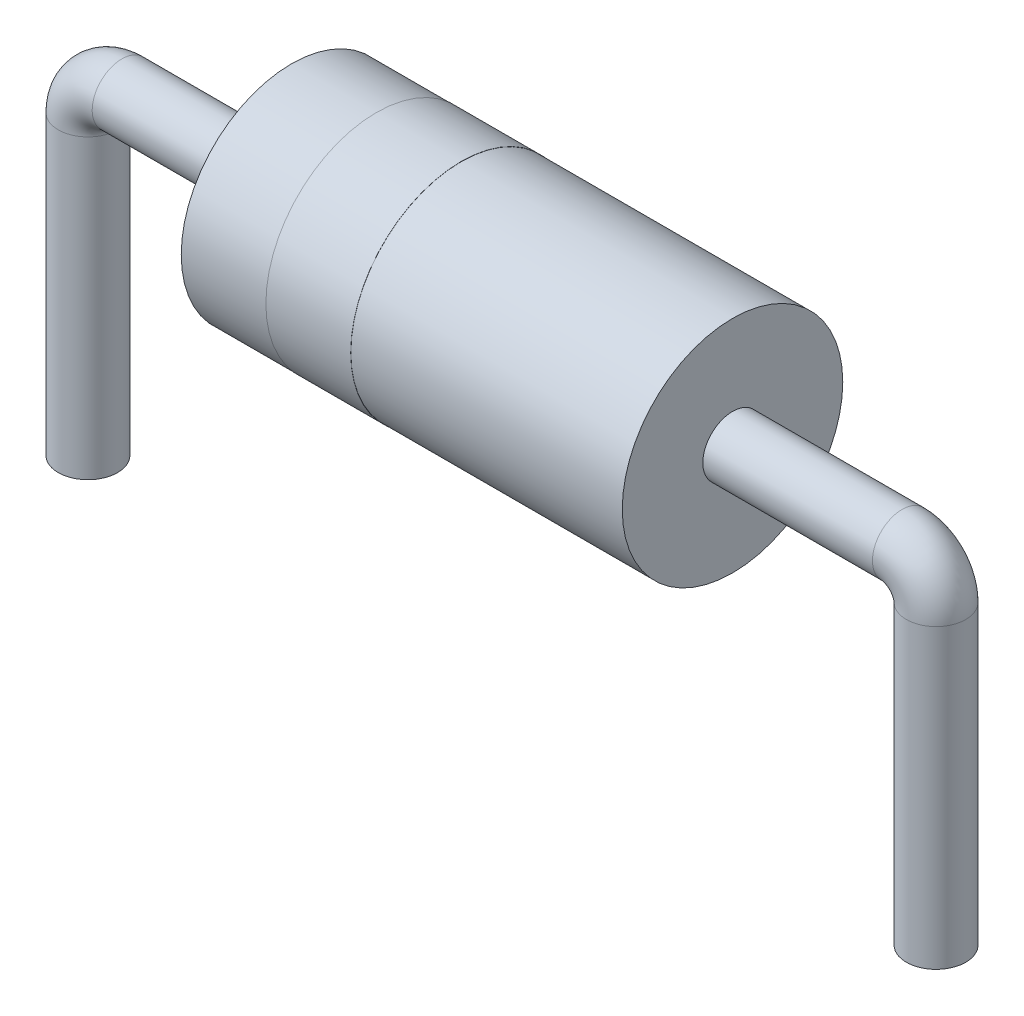
from build123d import *

# Parameters (mm, degrees)
SKIZZE1_R                       = 1.3
AUFSATZ_LINEAR_AUSTRAGEN1_DEPTH = 5.2
SKIZZE4_R                       = 1.302
AUFSATZ_LINEAR_AUSTRAGEN2_DEPTH = 1
SKIZZE10_R                      = 0.35
SKIZZE12_R                      = 0.35


with BuildPart() as part:
    # Skizze1 → Aufsatz-Linear austragen1 (new body)
    with BuildSketch(Plane(origin=(0, 0, 0), x_dir=(0, 0, -1), z_dir=(1, 0, 0))):
        Circle(SKIZZE1_R)
    extrude(amount=AUFSATZ_LINEAR_AUSTRAGEN1_DEPTH)

    # Skizze4 → Aufsatz-Linear austragen2 (add)
    with BuildSketch(Plane.ZY.offset(-2)):
        Circle(SKIZZE4_R)
    extrude(amount=AUFSATZ_LINEAR_AUSTRAGEN2_DEPTH)

    # Austragung3: sweep along a path in Skizze11
    with BuildLine(Plane.XY) as austragung3_path:
        Line((5.2, 0), (7.2, 0))
        ThreePointArc((7.2, 0), (7.482842712, -0.117157288), (7.6, -0.4))
        Line((7.6, -0.4), (7.6, -3.9))
    # Skizze10 → Austragung3 (sweep)
    with BuildSketch(Plane(origin=(5.2, 0, 0), x_dir=(0, 0, -1), z_dir=(1, 0, 0))):
        Circle(SKIZZE10_R)
    sweep(path=austragung3_path.line)

    # Austragung4: sweep along a path in Skizze13
    with BuildLine(Plane.XY) as austragung4_path:
        Line((0, 0), (-2, 0))
        ThreePointArc((-2, 0), (-2.282842712, -0.117157288), (-2.4, -0.4))
        Line((-2.4, -0.4), (-2.4, -3.9))
    # Skizze12 → Austragung4 (sweep)
    with BuildSketch(Plane.ZY):
        Circle(SKIZZE12_R)
    sweep(path=austragung4_path.line)


solid = part.part
